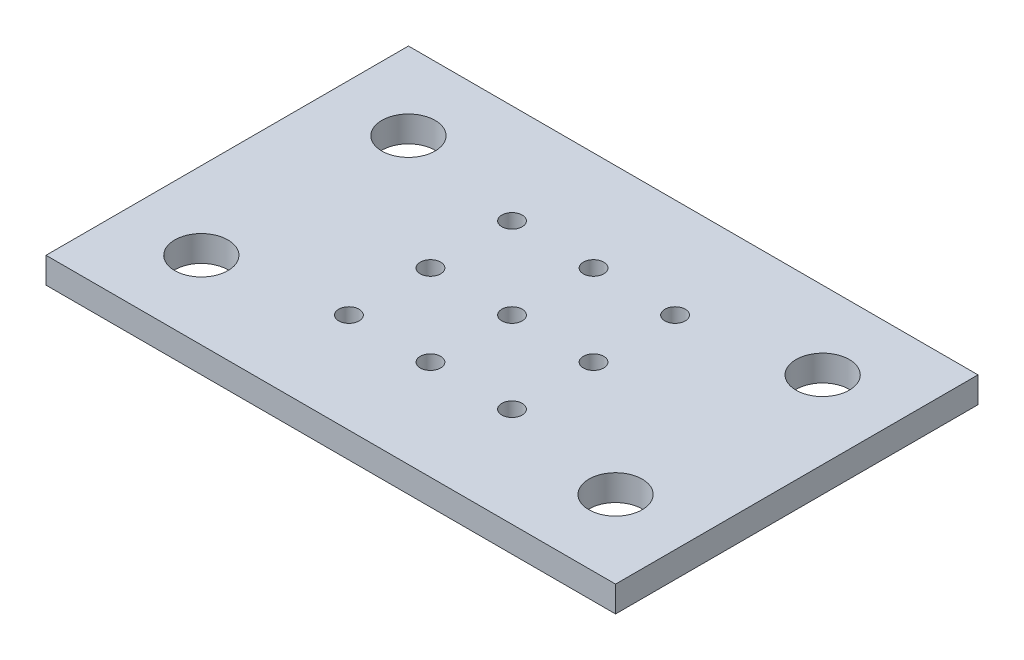
from build123d import *

# Parameters (mm, degrees)
SKETCH1_W           = 69.85
SKETCH1_H           = 44.45
SKETCH1_R           = 1.25
SKETCH1_R_2         = 3.2639
BOSS_EXTRUDE1_DEPTH = 3.175


with BuildPart() as part:
    # Sketch1 → Boss-Extrude1 (new body)
    with BuildSketch(Plane(origin=(0, 0, 0), x_dir=(1, 0, 0), z_dir=(0, 1, 0))):
        with Locations((34.925, 22.225)):
            Rectangle(SKETCH1_W, SKETCH1_H)
        with Locations((24.925, 12.225)):
            Circle(SKETCH1_R, mode=Mode.SUBTRACT)
        with Locations((34.925, 12.225)):
            Circle(SKETCH1_R, mode=Mode.SUBTRACT)
        with Locations((44.925, 12.225)):
            Circle(SKETCH1_R, mode=Mode.SUBTRACT)
        with Locations((24.925, 32.225)):
            Circle(SKETCH1_R, mode=Mode.SUBTRACT)
        with Locations((24.925, 22.225)):
            Circle(SKETCH1_R, mode=Mode.SUBTRACT)
        with Locations((34.925, 32.225)):
            Circle(SKETCH1_R, mode=Mode.SUBTRACT)
        with Locations((44.925, 32.225)):
            Circle(SKETCH1_R, mode=Mode.SUBTRACT)
        with Locations((44.925, 22.225)):
            Circle(SKETCH1_R, mode=Mode.SUBTRACT)
        with Locations((34.925, 22.225)):
            Circle(SKETCH1_R, mode=Mode.SUBTRACT)
        with Locations((60.325, 9.525)):
            Circle(SKETCH1_R_2, mode=Mode.SUBTRACT)
        with Locations((9.525, 9.525)):
            Circle(SKETCH1_R_2, mode=Mode.SUBTRACT)
        with Locations((60.325, 34.925)):
            Circle(SKETCH1_R_2, mode=Mode.SUBTRACT)
        with Locations((9.525, 34.925)):
            Circle(SKETCH1_R_2, mode=Mode.SUBTRACT)
    extrude(amount=BOSS_EXTRUDE1_DEPTH)


solid = part.part
